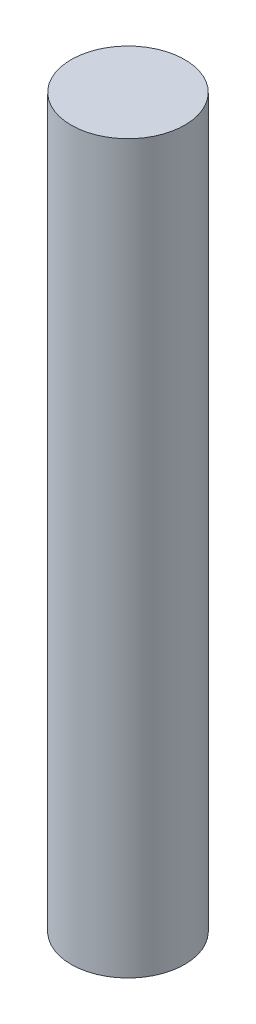
from build123d import *

# Parameters (mm, degrees)
CROQUIS1_R              = 0.5
SALIENTE_EXTRUIR1_DEPTH = 6.4


with BuildPart() as part:
    # Croquis1 → Saliente-Extruir1 (new body)
    with BuildSketch(Plane(origin=(0, 0, 0), x_dir=(1, 0, 0), z_dir=(0, 1, 0))):
        Circle(CROQUIS1_R)
    extrude(amount=SALIENTE_EXTRUIR1_DEPTH)


solid = part.part
